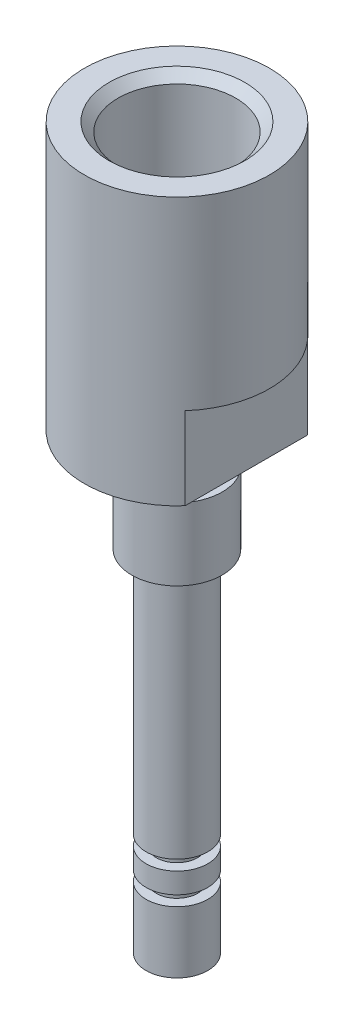
from build123d import *

# Parameters (mm, degrees)
SKETCH17_R                    = 1.5
CUT_EXTRUDE1_DEPTH            = 65
G1_4_TAPPED_HOLE1_D           = 11.445
G1_4_TAPPED_HOLE1_DEPTH       = 22
G1_4_TAPPED_HOLE1_CSINK_D     = 13.207
G1_4_TAPPED_HOLE1_CSINK_ANGLE = 90
G1_4_TAPPED_HOLE1_TIP         = 3.438424892
SKETCH18_W                    = 13.595594723
SKETCH18_H                    = 16.071338344
CUT_EXTRUDE2_DEPTH            = 8


with BuildPart() as part:
    # Sketch1 → Revolve1 (revolve)
    with BuildSketch(Plane.XY):
        Polygon((-0.75, 0), (-0.75, 70), (-9, 70), (-9, 44), (-3, 44), (-3, 41), (-4.396039606, 41), (-4.396039606, 34), (-3, 34), (-3, 10), (-2, 10), (-2, 9), (-3, 9), (-3, 7), (-2, 7), (-2, 6), (-3, 6), (-3, 0), align=None)
    revolve(axis=Axis((0, 0, 0), (0, 1, 0)))

    # Sketch17 → Cut-Extrude1 (cut)
    with BuildSketch(Plane(origin=(0, 70, 0), x_dir=(1, 0, 0), z_dir=(0, 1, 0))):
        Circle(SKETCH17_R)
    extrude(amount=-CUT_EXTRUDE1_DEPTH, mode=Mode.SUBTRACT)

    # G1/4 Tapped Hole1
    with Locations(Plane(origin=(0, 70, 0), x_dir=(1, 0, 0), z_dir=(0, 1, 0))):
        with Locations((0, 0)):
            CounterSinkHole(G1_4_TAPPED_HOLE1_D / 2, G1_4_TAPPED_HOLE1_CSINK_D / 2, depth=G1_4_TAPPED_HOLE1_DEPTH, counter_sink_angle=G1_4_TAPPED_HOLE1_CSINK_ANGLE)
            with Locations((0, 0, -(G1_4_TAPPED_HOLE1_DEPTH + G1_4_TAPPED_HOLE1_TIP / 2))):  # 118° drill point
                Cone(0, G1_4_TAPPED_HOLE1_D / 2, G1_4_TAPPED_HOLE1_TIP, mode=Mode.SUBTRACT)

    # Sketch18 → Cut-Extrude2 (cut)
    with BuildSketch(Plane.XZ.offset(-44)):
        with Locations((-13.547797362, 0)):
            Rectangle(SKETCH18_W, SKETCH18_H)
        with Locations((13.547797362, 0)):
            Rectangle(SKETCH18_W, SKETCH18_H)
    extrude(amount=-CUT_EXTRUDE2_DEPTH, mode=Mode.SUBTRACT)


solid = part.part
